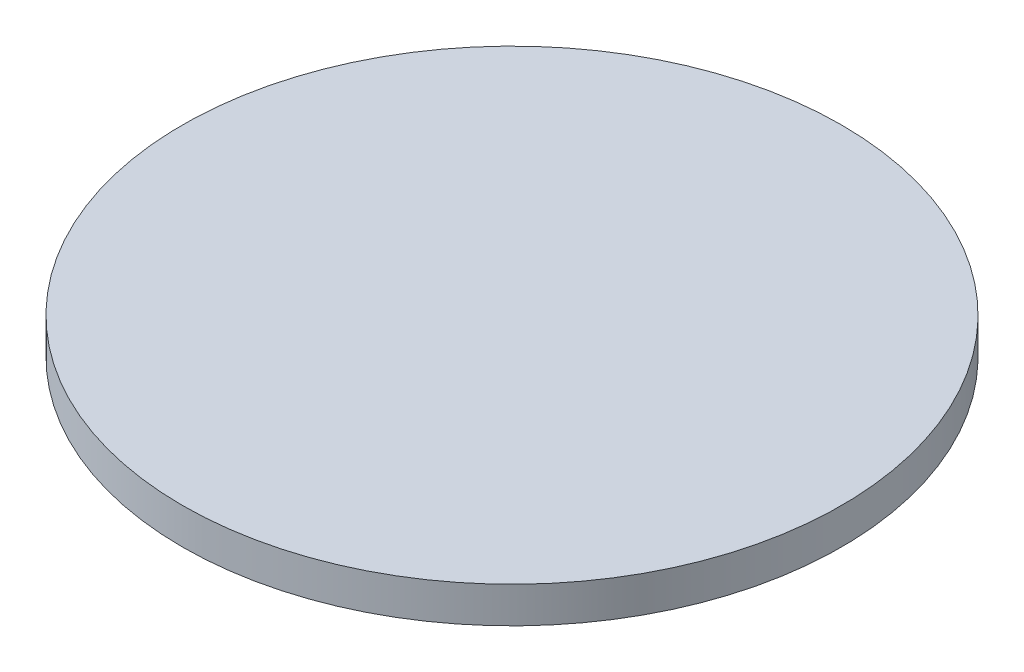
from build123d import *

# Parameters (mm, degrees)
SKETCH1_R           = 64
BOSS_EXTRUDE1_DEPTH = 7


with BuildPart() as part:
    # Sketch1 → Boss-Extrude1 (new body)
    with BuildSketch(Plane(origin=(0, 0, 0), x_dir=(1, 0, 0), z_dir=(0, 1, 0))):
        Circle(SKETCH1_R)
    extrude(amount=BOSS_EXTRUDE1_DEPTH)


solid = part.part
